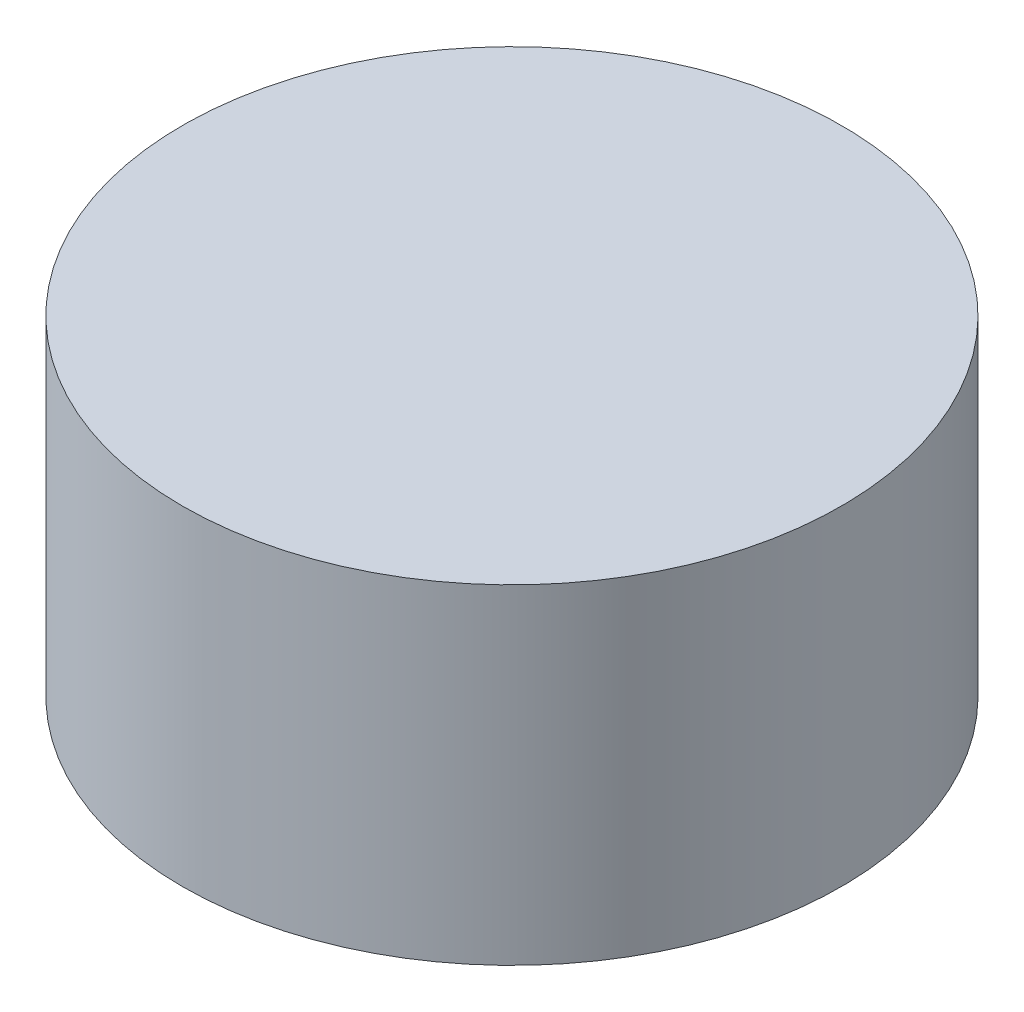
from build123d import *

# Parameters (mm, degrees)
SKETCH1_R           = 8
BOSS_EXTRUDE1_DEPTH = 8


with BuildPart() as part:
    # Sketch1 → Boss-Extrude1 (new body)
    with BuildSketch(Plane(origin=(0, 0, 0), x_dir=(1, 0, 0), z_dir=(0, 1, 0))):
        Circle(SKETCH1_R)
    extrude(amount=BOSS_EXTRUDE1_DEPTH)


solid = part.part
